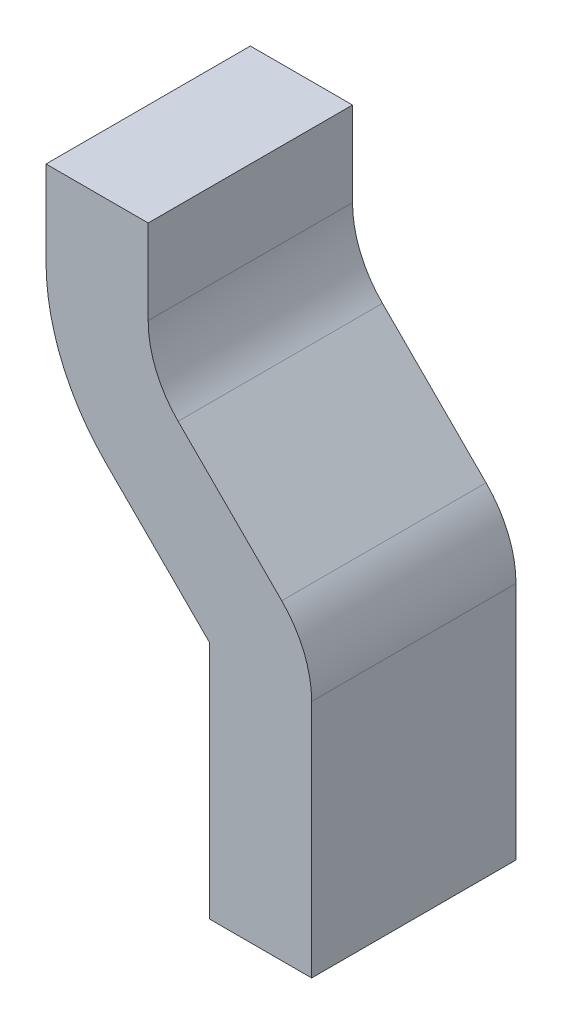
from build123d import *

# Parameters (mm, degrees)
BOSS_EXTRU_1_DEPTH = 1


with BuildPart() as part:
    # Esquisse1 → Boss.-Extru.1 (new body)
    with BuildSketch(Plane.XY):
        with BuildLine():
            Line((0, 0), (0, 1.172060256))
            Line((0, 1.172060256), (-0.507106781, 1.679167038))
            ThreePointArc((-0.507106781, 1.679167038), (-0.723879533, 2.003590386), (-0.8, 2.386273819))
            Line((-0.8, 2.386273819), (-0.8, 2.8))
            Line((-0.8, 2.8), (-0.3, 2.8))
            Line((-0.3, 2.8), (-0.3, 2.386273819))
            ThreePointArc((-0.3, 2.386273819), (-0.261939766, 2.194932103), (-0.153553391, 2.032720428))
            Line((-0.153553391, 2.032720428), (0.353553391, 1.525613647))
            ThreePointArc((0.353553391, 1.525613647), (0.461939766, 1.363401973), (0.5, 1.172060256))
            Line((0.5, 1.172060256), (0.5, 0))
            Line((0.5, 0), (0, 0))
        make_face()
    extrude(amount=BOSS_EXTRU_1_DEPTH)


solid = part.part
